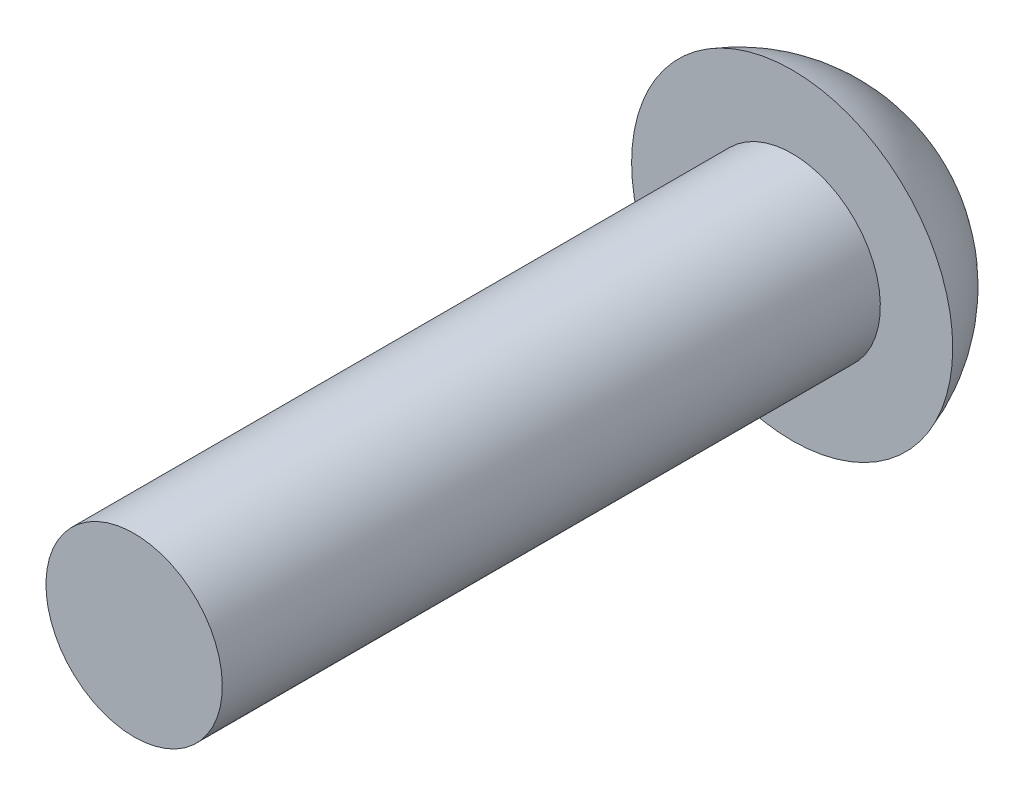
from build123d import *


with BuildPart() as part:
    # Sketch2 → Revolve1 (revolve)
    with BuildSketch(Plane(origin=(0, 0, 0), x_dir=(0, 0, -1), z_dir=(1, 0, 0))):
        with BuildLine():
            Line((0, 0), (0, 1.7018))
            Line((0, 1.7018), (12.7, 1.7018))
            Line((12.7, 1.7018), (12.7, 3.0988))
            ThreePointArc((12.7, 3.0988), (14.318092498, 1.910410982), (14.9352, 0))
            Line((14.9352, 0), (0, 0))
        make_face()
    revolve(axis=Axis((0, 0, 0), (0, 0, -1)))


solid = part.part
